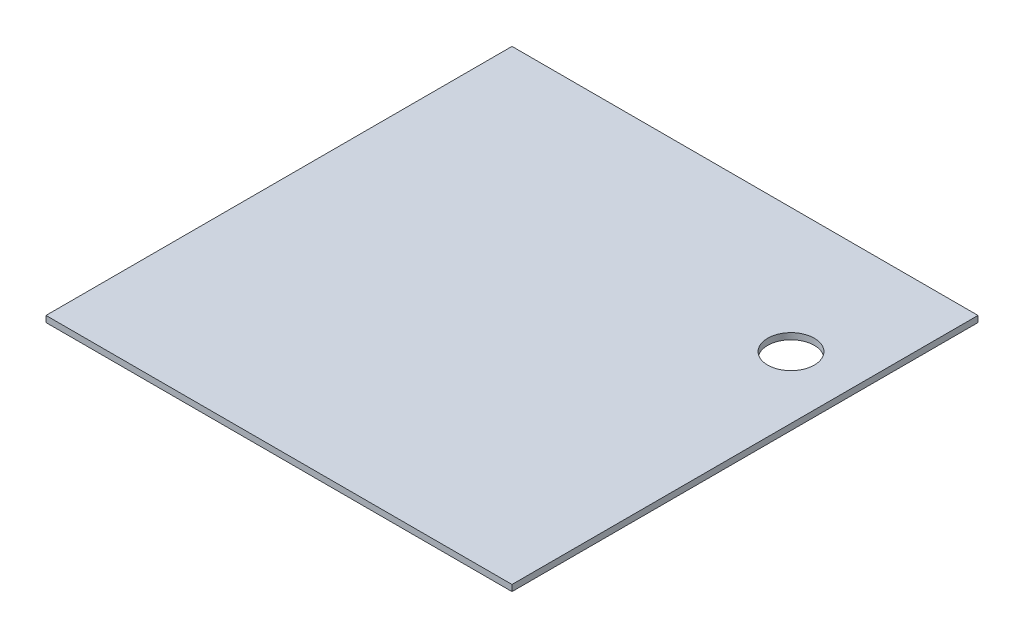
from build123d import *

# Parameters (mm, degrees)
SKETCH1_W           = 150
SKETCH1_H           = 150
BOSS_EXTRUDE1_DEPTH = 2
CUT_EXTRUDE1_REACH  = 4
SKETCH5_R           = 7.5


with BuildPart() as part:
    # Sketch1 → Boss-Extrude1 (new body)
    with BuildSketch(Plane(origin=(0, 0, 0), x_dir=(1, 0, 0), z_dir=(0, 1, 0))):
        Rectangle(SKETCH1_W, SKETCH1_H)
    extrude(amount=BOSS_EXTRUDE1_DEPTH)

    # Sketch5 → Cut-Extrude1 (cut, up to next)
    with BuildSketch(Plane(origin=(0, 2, 0), x_dir=(1, 0, 0), z_dir=(0, 1, 0)), mode=Mode.PRIVATE) as cut_extrude1_sk1:
        with Locations((55, 34.807)):
            Circle(SKETCH5_R)
    cut_extrude1_tool1 = extrude(cut_extrude1_sk1.sketch, amount=-CUT_EXTRUDE1_REACH, mode=Mode.PRIVATE) & part.part
    add(cut_extrude1_tool1.solids().sort_by_distance((55, 2, -34.807))[0], mode=Mode.SUBTRACT)


solid = part.part
